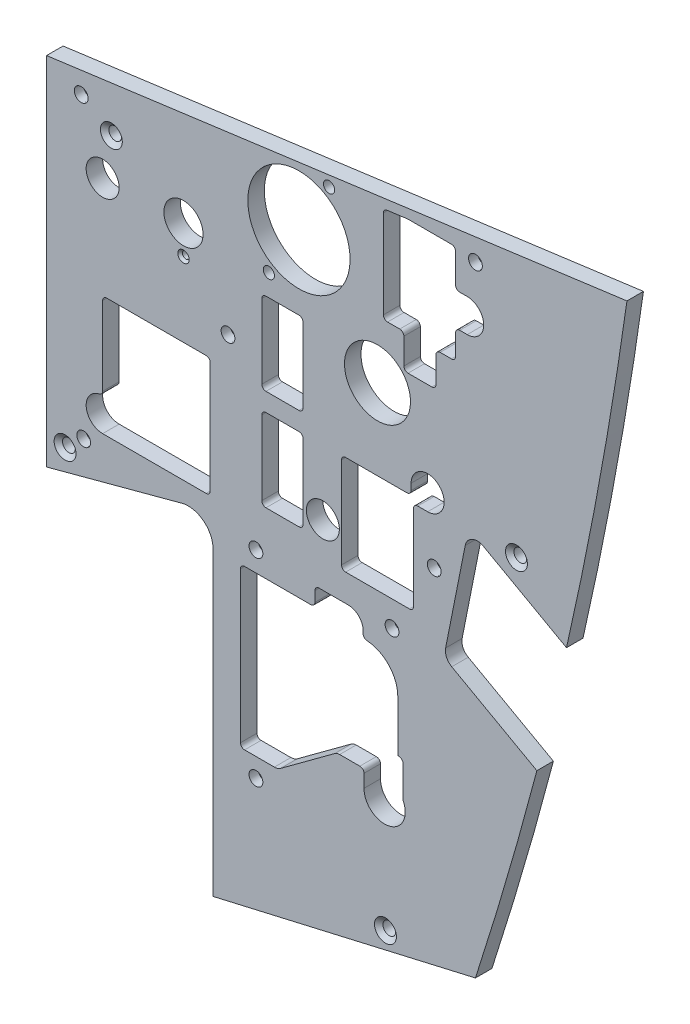
from build123d import *

# Parameters (mm, degrees)
BOSS_EXTRUDE1_DEPTH                               = 6.35
CUT_EXTRUDE1_DEPTH                                = 3445.149264037
SKETCH16_R                                        = 19.685
CUT_EXTRUDE2_DEPTH                                = 3441.935692786
HOLE1_AT_2_COUNT                                  = 2
HOLE1_AT_2_PITCH                                  = 119.24757236
HOLE1_AT_3_COUNT                                  = 2
HOLE1_AT_3_PITCH                                  = 110.986721534
HOLE1_AT_4_COUNT                                  = 2
HOLE1_AT_4_PITCH                                  = 153.074558064
HOLE1_AT_5_COUNT                                  = 2
HOLE1_AT_5_PITCH                                  = 201.938172537
HOLE1_AT_6_COUNT                                  = 2
HOLE1_AT_6_PITCH                                  = 141.789371247
HOLE1_AT_7_COUNT                                  = 2
HOLE1_AT_7_PITCH                                  = 161.907950567
HOLE1_AT_8_COUNT                                  = 2
HOLE1_AT_8_PITCH                                  = 230.363901281
F_6_CLEARANCE_HOLE1_D                             = 4.3053
SKETCH8_R                                         = 6.35
SKETCH8_W                                         = 15.875
SKETCH8_H                                         = 31.75
SKETCH8_R_2                                       = 12.7
BOSS_EXTRUDE4_DEPTH                               = 6.35
BOSS_EXTRUDE5_DEPTH                               = 6.35
FILLET1_R                                         = 1.5875
FILLET2_R                                         = 4.7625
CSK_FOR_8_FLAT_HEAD_MACHINE_SCREW_100_D           = 4.9149
CSK_FOR_8_FLAT_HEAD_MACHINE_SCREW_100_CSINK_D     = 8.4328
CSK_FOR_8_FLAT_HEAD_MACHINE_SCREW_100_CSINK_ANGLE = 100
F_9_16_CLEARANCE_HOLE1_D                          = 15.07998
CSK_FOR_2_FLAT_HEAD_MACHINE_SCREW1_D              = 2.7051
CSK_FOR_2_FLAT_HEAD_MACHINE_SCREW1_CSINK_D        = 4.3688
CSK_FOR_2_FLAT_HEAD_MACHINE_SCREW1_CSINK_ANGLE    = 82


with BuildPart() as part:
    # Sketch1 → Boss-Extrude1 (new body)
    with BuildSketch(Plane.XY):
        with BuildLine():
            Line((3063.004951447, 1044.559583645), (3063.004951447, 919.161653822))
            Line((3063.004951447, 919.161653822), (3164.268460554, 942.531700046))
            add(Edge.make_bspline(
                [(3164.268460554, 942.531700046), (3174.555103952, 973.758107079), (3183.862113846, 1005.38420927), (3192.178905159, 1037.697183634)],
                knots=[0.073605522, 0.073605522, 0.073605522, 0.073605522, 0.193443505, 0.193443505, 0.193443505, 0.193443505], degree=3))
            Line((3192.178905159, 1037.697183634), (3156.077631001, 1057.801137621))
            Line((3156.077631001, 1057.801137621), (3161.742294802, 1086.300863717))
            Line((3161.742294802, 1086.300863717), (3199.053930523, 1065.522887729))
            add(Edge.make_bspline(
                [(3199.053930523, 1065.522887729), (3209.83433854, 1111.042485424), (3218.693398597, 1158.04924886), (3225.6026318, 1207.31582086)],
                knots=[0.227626733, 0.227626733, 0.227626733, 0.227626733, 0.394301885, 0.394301885, 0.394301885, 0.394301885], degree=3))
            Line((3225.6026318, 1207.31582086), (2998.923757164, 1176.970694712))
            Line((2998.923757164, 1176.970694712), (2998.923757164, 1039.802301063))
            Line((2998.923757164, 1039.802301063), (3051.014700043, 1053.76002714))
            ThreePointArc((3051.014700043, 1053.76002714), (3059.278404059, 1052.116274211), (3063.004951447, 1044.559583645))
        make_face()
        with BuildLine():
            Line((3141.798754232, 1080.76821546), (3141.798754232, 1063.318414331))
            ThreePointArc((3141.798754232, 1063.318414331), (3141.330066584, 1062.18690214), (3140.19855446, 1061.718214331))
            Line((3140.19855446, 1061.718214331), (3005.273757092, 1061.718195164))
            ThreePointArc((3005.273757092, 1061.718195164), (3004.151224971, 1062.183163029), (3003.686256866, 1063.305695051))
            Line((3003.686256866, 1063.305695051), (3003.686245144, 1145.665194938))
            ThreePointArc((3003.686245144, 1145.665194938), (3004.151213016, 1146.787727075), (3005.273745054, 1147.252695186))
            Line((3005.273745054, 1147.252695186), (3005.908744671, 1147.252695254))
            ThreePointArc((3005.908744671, 1147.252695254), (3007.031276693, 1147.717663359), (3007.496244558, 1148.84019548))
            Line((3007.496244558, 1148.84019548), (3007.496242589, 1162.696016971))
            ThreePointArc((3007.496242589, 1162.696016971), (3007.961210415, 1163.818549052), (3009.083742364, 1164.283517197))
            Line((3009.083742364, 1164.283517197), (3012.258758066, 1164.283517648))
            ThreePointArc((3012.258758066, 1164.283517648), (3016.753873448, 1166.148383358), (3018.608741475, 1170.647633408))
            Line((3018.608741475, 1170.647633408), (3018.608740873, 1174.88088596))
            ThreePointArc((3018.608740873, 1174.88088596), (3019.002695145, 1175.927597629), (3019.989030664, 1176.454804919))
            Line((3019.989030664, 1176.454804919), (3036.868275535, 1178.676998342))
            ThreePointArc((3036.868275535, 1178.676998342), (3038.252348893, 1178.168513501), (3038.621106409, 1176.740846246))
            Line((3038.621106409, 1176.740846246), (3031.88970174, 1148.018483172))
            ThreePointArc((3031.88970174, 1148.018483172), (3031.806950167, 1147.214053621), (3031.930103254, 1146.414811455))
            Line((3031.930103254, 1146.414811455), (3037.83452165, 1125.926489722))
            ThreePointArc((3037.83452165, 1125.926489722), (3038.976284575, 1124.2687575), (3040.885361466, 1123.630694713))
            Line((3040.885361466, 1123.630694713), (3060.836248915, 1123.630694713))
            ThreePointArc((3060.836248915, 1123.630694713), (3061.95878093, 1123.165726728), (3062.423748915, 1122.043194713))
            Line((3062.423748915, 1122.043194713), (3062.423748915, 1118.868194713))
            ThreePointArc((3062.423748915, 1118.868194713), (3068.773748915, 1112.518194713), (3075.123748915, 1118.868194713))
            Line((3075.123748915, 1118.868194713), (3075.123748915, 1138.235694713))
            ThreePointArc((3075.123748915, 1138.235694713), (3075.5887169, 1139.358226728), (3076.711248915, 1139.823194713))
            Line((3076.711248915, 1139.823194713), (3108.256643371, 1139.823194713))
            ThreePointArc((3108.256643371, 1139.823194713), (3110.126802458, 1140.432433619), (3111.279245843, 1142.026341177))
            Line((3111.279245843, 1142.026341177), (3126.56576419, 1189.569583471))
            ThreePointArc((3126.56576419, 1189.569583471), (3127.060083558, 1190.302633376), (3127.869855096, 1190.657575421))
            Line((3127.869855096, 1190.657575421), (3155.879034385, 1194.345053829))
            ThreePointArc((3155.879034385, 1194.345053829), (3157.132956197, 1193.964680806), (3157.673744716, 1192.771135112))
            Line((3157.673744716, 1192.771135112), (3157.673744716, 1190.613729862))
            ThreePointArc((3157.673744716, 1190.613729862), (3159.533616655, 1186.123601801), (3164.023744716, 1184.263729862))
            Line((3164.023744716, 1184.263729862), (3167.198744716, 1184.263729862))
            ThreePointArc((3167.198744716, 1184.263729862), (3168.321276731, 1183.798761877), (3168.786244716, 1182.676229862))
            Line((3168.786244716, 1182.676229862), (3168.786244716, 1148.078239816))
            ThreePointArc((3168.786244716, 1148.078239816), (3168.321276811, 1146.955707881), (3167.198744941, 1146.490739816))
            Line((3167.198744941, 1146.490739816), (3162.436243814, 1146.490739139))
            ThreePointArc((3162.436243814, 1146.490739139), (3158.376709192, 1145.023641776), (3156.192988793, 1141.300261425))
            Line((3156.192988793, 1141.300261425), (3152.937962341, 1123.774429951))
            ThreePointArc((3152.937962341, 1123.774429951), (3152.917957765, 1123.63010065), (3152.911270795, 1123.484545113))
            Line((3152.911270795, 1123.484545113), (3152.911270795, 1088.70571546))
            ThreePointArc((3152.911270795, 1088.70571546), (3152.44630281, 1087.583183445), (3151.323770795, 1087.11821546))
            Line((3151.323770795, 1087.11821546), (3148.148754232, 1087.11821546))
            ThreePointArc((3148.148754232, 1087.11821546), (3143.658626172, 1085.258343521), (3141.798754232, 1080.76821546))
        make_face(mode=Mode.SUBTRACT)
        with BuildLine():
            Line((3086.087201447, 970.357569713), (3119.749985468, 970.357569713))
            ThreePointArc((3119.749985468, 970.357569713), (3120.138791835, 970.434908108), (3120.468405958, 970.655149223))
            Line((3120.468405958, 970.655149223), (3137.557996937, 987.744740203))
            ThreePointArc((3137.557996937, 987.744740203), (3137.778238052, 988.074354325), (3137.855576447, 988.463160692))
            Line((3137.855576447, 988.463160692), (3137.855576447, 1045.938444713))
            ThreePointArc((3137.855576447, 1045.938444713), (3137.557996937, 1046.656865203), (3136.839576447, 1046.954444713))
            Line((3136.839576447, 1046.954444713), (3131.108701447, 1046.954444713))
            ThreePointArc((3131.108701447, 1046.954444713), (3127.741105402, 1048.349348668), (3126.346201447, 1051.716944713))
            Line((3126.346201447, 1051.716944713), (3126.346201447, 1057.447819713))
            ThreePointArc((3126.346201447, 1057.447819713), (3126.048621937, 1058.166240203), (3125.330201447, 1058.463819713))
            Line((3125.330201447, 1058.463819713), (3085.293451447, 1058.463819713))
            ThreePointArc((3085.293451447, 1058.463819713), (3084.575030958, 1058.166240203), (3084.277451447, 1057.447819713))
            Line((3084.277451447, 1057.447819713), (3084.277451447, 1052.510694713))
            ThreePointArc((3084.277451447, 1052.510694713), (3082.882547493, 1049.143098667), (3079.514951447, 1047.748194713))
            Line((3079.514951447, 1047.748194713), (3074.577826447, 1047.748194713))
            ThreePointArc((3074.577826447, 1047.748194713), (3073.859405958, 1047.450615203), (3073.561826447, 1046.732194713))
            Line((3073.561826447, 1046.732194713), (3073.561826447, 982.882944713))
            ThreePointArc((3073.561826447, 982.882944713), (3073.859405958, 982.164524223), (3074.577826447, 981.866944713))
            Line((3074.577826447, 981.866944713), (3080.308701447, 981.866944713))
            ThreePointArc((3080.308701447, 981.866944713), (3083.676297493, 980.472040758), (3085.071201447, 977.104444713))
            Line((3085.071201447, 977.104444713), (3085.071201447, 971.373569713))
            ThreePointArc((3085.071201447, 971.373569713), (3085.368780958, 970.655149223), (3086.087201447, 970.357569713))
        make_face(mode=Mode.SUBTRACT)
    extrude(amount=-BOSS_EXTRUDE1_DEPTH)

    # Sketch2 → Cut-Extrude1 (cut, through all)
    with BuildSketch(Plane.XY):
        with BuildLine():
            Line((3192.178905159, 1037.697183634), (3156.077631001, 1057.801137621))
            Line((3156.077631001, 1057.801137621), (3161.742294802, 1086.300863717))
            Line((3161.742294802, 1086.300863717), (3199.053930523, 1065.522887729))
            add(Edge.make_bspline(
                [(3199.053930523, 1065.522887729), (3209.83433854, 1111.042485424), (3218.693398597, 1158.04924886), (3225.602631801, 1207.31582086)],
                knots=[0.227626733, 0.227626733, 0.227626733, 0.227626733, 0.394301885, 0.394301885, 0.394301885, 0.394301885], degree=3))
            Line((3225.602631801, 1207.31582086), (3222.334973685, 1206.878384871))
            add(Edge.make_bspline(
                [(3199.066872029, 1079.630557452), (3199.348827276, 1080.872127049), (3200.919170922, 1087.829294258), (3204.958331198, 1106.340377978), (3209.61532338, 1129.652293978), (3213.911729082, 1153.321830635), (3216.952381515, 1171.25706578), (3219.335387039, 1186.36829019), (3221.106417414, 1198.260437059), (3221.944482294, 1204.104861355), (3222.334973685, 1206.878384871)],
                knots=[0.243930295, 0.243930295, 0.243930295, 0.243930295, 0.248461127, 0.269295521, 0.310964309, 0.331798703, 0.352633097, 0.373467491, 0.383884688, 0.393307081, 0.393307081, 0.393307081, 0.393307081], degree=3))
            Line((3199.066872029, 1079.630557452), (3161.353699672, 1100.632139788))
            Line((3161.353699672, 1100.632139788), (3151.862439008, 1052.880262758))
            Line((3151.862439008, 1052.880262758), (3187.665173517, 1032.942558509))
            add(Edge.make_bspline(
                [(3164.016888783, 951.998641164), (3165.625997339, 956.980849059), (3169.69138435, 969.794206523), (3175.977462125, 990.567604952), (3181.626956674, 1010.422414131), (3185.462648104, 1024.578734882), (3187.09667721, 1030.768886559), (3187.665173517, 1032.942558509)],
                knots=[0.084451096, 0.084451096, 0.084451096, 0.084451096, 0.103565018, 0.133524514, 0.163484009, 0.178463757, 0.186560537, 0.186560537, 0.186560537, 0.186560537], degree=3))
            Line((3164.016888783, 951.998641164), (3063.004951447, 928.686653822))
            Line((3063.004951447, 928.686653822), (3063.004951447, 919.161653822))
            Line((3063.004951447, 919.161653822), (3164.268460554, 942.531700046))
            add(Edge.make_bspline(
                [(3164.268460554, 942.531700046), (3174.555103952, 973.758107079), (3183.862113846, 1005.38420927), (3192.178905159, 1037.697183634)],
                knots=[0.073605522, 0.073605522, 0.073605522, 0.073605522, 0.193443505, 0.193443505, 0.193443505, 0.193443505], degree=3))
        make_face()
    extrude(amount=-CUT_EXTRUDE1_DEPTH, mode=Mode.SUBTRACT)

    # Sketch16 → Cut-Extrude2 (cut, through all)
    with BuildSketch(Plane(origin=(0, 0, -6.35), x_dir=(-1, 0, 0), z_dir=(0, 0, -1))):
        with Locations(Location((-3096.078757164, 1167.445694712, 0), (0, 0, 90))):
            Circle(SKETCH16_R)
    extrude(amount=-CUT_EXTRUDE2_DEPTH, mode=Mode.SUBTRACT)

    # Sketch5 → Hole1 (revolve, cut)
    with BuildSketch(Plane(origin=(3164.023744716, 1190.613729862, 0), x_dir=(0, -1, 0), z_dir=(1, 0, 0))):
        Polygon((0, 0), (0, 3.429), (2.5273, 3.429), (2.6543, 0), align=None)
    hole1 = revolve(axis=Axis((3164.023744716, 1190.613729862, -110), (0, 0, 1)), mode=Mode.SUBTRACT)

    # Hole1 at 2: Hole1 ×2
    with Locations(*[Vector(-0.7987583639260228, -0.601651955916561, 0) * (i * HOLE1_AT_2_PITCH) for i in range(1, HOLE1_AT_2_COUNT)]):
        add(hole1, mode=Mode.SUBTRACT)

    # Hole1 at 3: Hole1 ×2
    with Locations(*[Vector(-0.14303504296543185, -0.9897176246202132, 0) * (i * HOLE1_AT_3_PITCH) for i in range(1, HOLE1_AT_3_COUNT)]):
        add(hole1, mode=Mode.SUBTRACT)

    # Hole1 at 4: Hole1 ×2
    with Locations(*[Vector(-0.9914448845748092, -0.13052601599084906, 0) * (i * HOLE1_AT_4_PITCH) for i in range(1, HOLE1_AT_4_COUNT)]):
        add(hole1, mode=Mode.SUBTRACT)

    # Hole1 at 5: Hole1 ×2
    with Locations(*[Vector(-0.7468250559832259, -0.6650205528821282, 0) * (i * HOLE1_AT_5_PITCH) for i in range(1, HOLE1_AT_5_COUNT)]):
        add(hole1, mode=Mode.SUBTRACT)

    # Hole1 at 6: Hole1 ×2
    with Locations(*[Vector(-0.2265423210908874, -0.9740013227684824, 0) * (i * HOLE1_AT_6_PITCH) for i in range(1, HOLE1_AT_6_COUNT)]):
        add(hole1, mode=Mode.SUBTRACT)

    # Hole1 at 7: Hole1 ×2
    with Locations(*[Vector(-0.52195579631539, -0.852972535720094, 0) * (i * HOLE1_AT_7_PITCH) for i in range(1, HOLE1_AT_7_COUNT)]):
        add(hole1, mode=Mode.SUBTRACT)

    # Hole1 at 8: Hole1 ×2
    with Locations(*[Vector(-0.36684911480554966, -0.9302804560810599, 0) * (i * HOLE1_AT_8_PITCH) for i in range(1, HOLE1_AT_8_COUNT)]):
        add(hole1, mode=Mode.SUBTRACT)

    # #6 Clearance Hole1 (through all)
    with Locations(Plane.XY):
        with Locations((3079.514951447, 976.310694713), (3079.514951447, 1052.510694713), (3131.902451447, 1052.510694713), (3013.211257705, 1056.320694713), (3012.258757164, 1170.633517648), (3068.773748915, 1118.868194713), (3148.148754232, 1080.76821546), (3164.023744716, 1190.613729862), (3107.667507164, 1187.517998508), (3084.490007164, 1147.373390916)):
            Hole(F_6_CLEARANCE_HOLE1_D / 2)

    # Sketch8 → Boss-Extrude4 (add)
    with BuildSketch(Plane(origin=(0, 0, -6.35), x_dir=(-1, 0, 0), z_dir=(0, 0, -1))):
        with BuildLine():
            Line((-3020.513756037, 1107.681631415), (-3020.513756037, 1074.418198411))
            ThreePointArc((-3020.513756037, 1074.418198411), (-3014.163755495, 1068.068197829), (-3020.51375612, 1061.718197329))
            Line((-3020.51375612, 1061.718197329), (-3005.273757092, 1061.718195164))
            ThreePointArc((-3005.273757092, 1061.718195164), (-3004.151224971, 1062.183163029), (-3003.686256866, 1063.305695051))
            Line((-3003.686256866, 1063.305695051), (-3003.686245144, 1145.665194938))
            ThreePointArc((-3003.686245144, 1145.665194938), (-3004.151213016, 1146.787727075), (-3005.273745054, 1147.252695186))
            Line((-3005.273745054, 1147.252695186), (-3005.908744671, 1147.252695254))
            ThreePointArc((-3005.908744671, 1147.252695254), (-3007.031276693, 1147.717663359), (-3007.496244558, 1148.84019548))
            Line((-3007.496244558, 1148.84019548), (-3007.496242589, 1162.696016971))
            ThreePointArc((-3007.496242589, 1162.696016971), (-3007.961210415, 1163.818549052), (-3009.083742364, 1164.283517197))
            Line((-3009.083742364, 1164.283517197), (-3012.258758066, 1164.283517648))
            ThreePointArc((-3012.258758066, 1164.283517648), (-3016.753873448, 1166.148383358), (-3018.608741475, 1170.647633408))
            Line((-3018.608741475, 1170.647633408), (-3018.608740873, 1174.88088596))
            ThreePointArc((-3018.608740873, 1174.88088596), (-3019.002695145, 1175.927597629), (-3019.989030664, 1176.454804919))
            Line((-3019.989030664, 1176.454804919), (-3036.868275535, 1178.676998342))
            ThreePointArc((-3036.868275535, 1178.676998342), (-3038.252348893, 1178.168513501), (-3038.621106409, 1176.740846246))
            Line((-3038.621106409, 1176.740846246), (-3031.88970174, 1148.018483172))
            ThreePointArc((-3031.88970174, 1148.018483172), (-3031.806950167, 1147.214053621), (-3031.930103254, 1146.414811455))
            Line((-3031.930103254, 1146.414811455), (-3037.83452165, 1125.926489722))
            ThreePointArc((-3037.83452165, 1125.926489722), (-3038.976284575, 1124.2687575), (-3040.885361466, 1123.630694713))
            Line((-3040.885361466, 1123.630694713), (-3060.836248915, 1123.630694713))
            ThreePointArc((-3060.836248915, 1123.630694713), (-3061.95878093, 1123.165726728), (-3062.423748915, 1122.043194713))
            Line((-3062.423748915, 1122.043194713), (-3062.423748915, 1118.868194713))
            ThreePointArc((-3062.423748915, 1118.868194713), (-3068.773748915, 1112.518194713), (-3075.123748915, 1118.868194713))
            Line((-3075.123748915, 1118.868194713), (-3075.123748915, 1138.235694713))
            ThreePointArc((-3075.123748915, 1138.235694713), (-3075.5887169, 1139.358226728), (-3076.711248915, 1139.823194713))
            Line((-3076.711248915, 1139.823194713), (-3108.256643371, 1139.823194713))
            ThreePointArc((-3108.256643371, 1139.823194713), (-3110.126802458, 1140.432433619), (-3111.279245843, 1142.026341177))
            Line((-3111.279245843, 1142.026341177), (-3126.56576419, 1189.569583471))
            ThreePointArc((-3126.56576419, 1189.569583471), (-3127.060083558, 1190.302633376), (-3127.869855096, 1190.657575421))
            Line((-3127.869855096, 1190.657575421), (-3128.588447605, 1190.752179919))
            Line((-3128.588447605, 1190.752179919), (-3128.588447605, 1153.771047149))
            Line((-3128.588447605, 1153.771047149), (-3136.469706644, 1153.771047149))
            Line((-3136.469706644, 1153.771047149), (-3136.469706644, 1140.63864551))
            Line((-3136.469706644, 1140.63864551), (-3148.824486801, 1140.63864551))
            Line((-3148.824486801, 1140.63864551), (-3148.824486801, 1153.771047149))
            Line((-3148.824486801, 1153.771047149), (-3156.379047605, 1153.771047149))
            Line((-3156.379047605, 1153.771047149), (-3156.379047605, 1164.905716362))
            Line((-3156.379047605, 1164.905716362), (-3160.848758292, 1164.905716362))
            ThreePointArc((-3160.848758292, 1164.905716362), (-3167.198758292, 1171.255716362), (-3160.848758292, 1177.605716362))
            Line((-3160.848758292, 1177.605716362), (-3156.379047605, 1177.605716362))
            Line((-3156.379047605, 1177.605716362), (-3156.379047605, 1191.988194556))
            Line((-3156.379047605, 1191.988194556), (-3137.976910864, 1191.988194556))
            Line((-3137.976910864, 1191.988194556), (-3155.879034385, 1194.345053829))
            ThreePointArc((-3155.879034385, 1194.345053829), (-3157.132956197, 1193.964680806), (-3157.673744716, 1192.771135112))
            Line((-3157.673744716, 1192.771135112), (-3157.673744716, 1190.613729862))
            ThreePointArc((-3157.673744716, 1190.613729862), (-3159.533616655, 1186.123601801), (-3164.023744716, 1184.263729862))
            Line((-3164.023744716, 1184.263729862), (-3167.198744716, 1184.263729862))
            ThreePointArc((-3167.198744716, 1184.263729862), (-3168.321276731, 1183.798761877), (-3168.786244716, 1182.676229862))
            Line((-3168.786244716, 1182.676229862), (-3168.786244716, 1148.078239816))
            ThreePointArc((-3168.786244716, 1148.078239816), (-3168.321276811, 1146.955707881), (-3167.198744941, 1146.490739816))
            Line((-3167.198744941, 1146.490739816), (-3162.436243814, 1146.490739139))
            ThreePointArc((-3162.436243814, 1146.490739139), (-3158.376709192, 1145.023641776), (-3156.192988793, 1141.300261425))
            Line((-3156.192988793, 1141.300261425), (-3152.937962341, 1123.774429951))
            ThreePointArc((-3152.937962341, 1123.774429951), (-3152.917957765, 1123.63010065), (-3152.911270795, 1123.484545113))
            Line((-3152.911270795, 1123.484545113), (-3152.911270795, 1088.70571546))
            ThreePointArc((-3152.911270795, 1088.70571546), (-3152.44630281, 1087.583183445), (-3151.323770795, 1087.11821546))
            Line((-3151.323770795, 1087.11821546), (-3148.148754232, 1087.11821546))
            ThreePointArc((-3148.148754232, 1087.11821546), (-3143.658626172, 1085.258343521), (-3141.798754232, 1080.76821546))
            Line((-3141.798754232, 1080.76821546), (-3141.798754232, 1063.318414331))
            ThreePointArc((-3141.798754232, 1063.318414331), (-3141.330066584, 1062.18690214), (-3140.19855446, 1061.718214331))
            Line((-3140.19855446, 1061.718214331), (-3061.926971874, 1061.71819787))
            Line((-3061.926971874, 1061.71819787), (-3061.926971874, 1107.681631415))
            Line((-3061.926971874, 1107.681631415), (-3020.513756037, 1107.681631415))
        make_face()
        with BuildLine():
            Line((-3112.459456626, 1062.331068799), (-3140.200056626, 1062.331068799))
            Line((-3140.200056626, 1062.331068799), (-3140.200056626, 1098.230715099))
            Line((-3140.200056626, 1098.230715099), (-3145.608758292, 1098.230715099))
            ThreePointArc((-3145.608758292, 1098.230715099), (-3150.098886352, 1109.07084316), (-3139.258758292, 1104.580715099))
            Line((-3139.258758292, 1104.580715099), (-3139.258758292, 1100.548216205))
            Line((-3139.258758292, 1100.548216205), (-3112.459456626, 1100.548216205))
            Line((-3112.459456626, 1100.548216205), (-3112.459456626, 1062.331068799))
        make_face(mode=Mode.SUBTRACT)
        with Locations(Location((-3105.286254999, 1075.370709371, 0), (0, 0, 90))):
            Circle(SKETCH8_R, mode=Mode.SUBTRACT)
        with Locations((-3089.728757164, 1084.310716418)):
            Rectangle(SKETCH8_W, SKETCH8_H, mode=Mode.SUBTRACT)
        with Locations((-3089.728757221, 1123.122716078)):
            Rectangle(SKETCH8_W, SKETCH8_H, mode=Mode.SUBTRACT)
        with Locations(Location((-3126.304753736, 1131.568216137, 0), (0, 0, 90))):
            Circle(SKETCH8_R_2, mode=Mode.SUBTRACT)
        with Locations(Location((-3020.513744842, 1146.87169787, 0), (0, 0, 90))):
            Circle(SKETCH8_R, mode=Mode.SUBTRACT)
        Polygon((-3128.588447605, 1191.988194556), (-3137.976910864, 1191.988194556), (-3128.588447605, 1190.752179919), align=None)
    extrude(amount=-BOSS_EXTRUDE4_DEPTH)

    # Sketch9 → Boss-Extrude5 (add)
    with BuildSketch(Plane(origin=(0, 0, -6.35), x_dir=(-1, 0, 0), z_dir=(0, 0, -1))):
        with BuildLine():
            Line((-3111.751124589, 1000.371317539), (-3121.107451447, 1000.371317539))
            Line((-3121.107451447, 1000.371317539), (-3121.107451447, 993.773194713))
            ThreePointArc((-3121.107451447, 993.773194713), (-3130.882615556, 986.051349281), (-3136.131551447, 997.348667645))
            Line((-3136.131551447, 997.348667645), (-3136.131551447, 1011.166317539))
            Line((-3136.131551447, 1011.166317539), (-3134.124951447, 1011.166317539))
            Line((-3134.124951447, 1011.166317539), (-3134.124951447, 1030.920694713))
            ThreePointArc((-3134.124951447, 1030.920694713), (-3130.177822405, 1040.122718947), (-3120.789951447, 1043.604809779))
            Line((-3120.789951447, 1043.604809779), (-3120.789951447, 1046.160694713))
            ThreePointArc((-3120.789951447, 1046.160694713), (-3119.116066702, 1050.201809967), (-3115.074951447, 1051.875694713))
            Line((-3115.074951447, 1051.875694713), (-3102.247951447, 1051.875694713))
            Line((-3102.247951447, 1051.875694713), (-3102.247951447, 1044.771182058))
            Line((-3102.247951447, 1044.771182058), (-3082.181951447, 1044.771182058))
            Line((-3082.181951447, 1044.771182058), (-3073.561826447, 1044.771182058))
            Line((-3073.561826447, 1044.771182058), (-3073.561826447, 1046.732194713))
            ThreePointArc((-3073.561826447, 1046.732194713), (-3073.859405958, 1047.450615203), (-3074.577826447, 1047.748194713))
            Line((-3074.577826447, 1047.748194713), (-3079.514951447, 1047.748194713))
            ThreePointArc((-3079.514951447, 1047.748194713), (-3082.882547493, 1049.143098667), (-3084.277451447, 1052.510694713))
            Line((-3084.277451447, 1052.510694713), (-3084.277451447, 1057.447819713))
            ThreePointArc((-3084.277451447, 1057.447819713), (-3084.575030958, 1058.166240203), (-3085.293451447, 1058.463819713))
            Line((-3085.293451447, 1058.463819713), (-3125.330201447, 1058.463819713))
            ThreePointArc((-3125.330201447, 1058.463819713), (-3126.048621937, 1058.166240203), (-3126.346201447, 1057.447819713))
            Line((-3126.346201447, 1057.447819713), (-3126.346201447, 1051.716944713))
            ThreePointArc((-3126.346201447, 1051.716944713), (-3127.741105402, 1048.349348668), (-3131.108701447, 1046.954444713))
            Line((-3131.108701447, 1046.954444713), (-3136.839576447, 1046.954444713))
            ThreePointArc((-3136.839576447, 1046.954444713), (-3137.557996937, 1046.656865203), (-3137.855576447, 1045.938444713))
            Line((-3137.855576447, 1045.938444713), (-3137.855576447, 988.463160692))
            ThreePointArc((-3137.855576447, 988.463160692), (-3137.778238052, 988.074354325), (-3137.557996937, 987.744740203))
            Line((-3137.557996937, 987.744740203), (-3120.468405958, 970.655149223))
            ThreePointArc((-3120.468405958, 970.655149223), (-3120.138791835, 970.434908108), (-3119.749985468, 970.357569713))
            Line((-3119.749985468, 970.357569713), (-3086.087201447, 970.357569713))
            ThreePointArc((-3086.087201447, 970.357569713), (-3085.368780958, 970.655149223), (-3085.071201447, 971.373569713))
            Line((-3085.071201447, 971.373569713), (-3085.071201447, 977.104444713))
            ThreePointArc((-3085.071201447, 977.104444713), (-3083.676297493, 980.472040758), (-3080.308701447, 981.866944713))
            Line((-3080.308701447, 981.866944713), (-3074.577826447, 981.866944713))
            ThreePointArc((-3074.577826447, 981.866944713), (-3073.859405958, 982.164524223), (-3073.561826447, 982.882944713))
            Line((-3073.561826447, 982.882944713), (-3073.561826447, 983.613194713))
            Line((-3073.561826447, 983.613194713), (-3086.617425772, 983.613194713))
            ThreePointArc((-3086.617425772, 983.613194713), (-3087.906471358, 983.819646673), (-3089.066564314, 984.41834966))
            Line((-3089.066564314, 984.41834966), (-3109.867171864, 999.75196758))
            ThreePointArc((-3109.867171864, 999.75196758), (-3110.759551061, 1000.212508339), (-3111.751124589, 1000.371317539))
        make_face()
    extrude(amount=-BOSS_EXTRUDE5_DEPTH)

    # Fillet1
    fillet1_edges = [part.edges().sort_by_distance(p)[0] for p in [
        (3139.258758292, 1100.548216205, -3.175),
        (3112.459456626, 1100.548216205, -3.175),
        (3112.459456626, 1062.331068799, -3.175),
        (3140.200056626, 1062.331068799, -3.175),
        (3140.200056626, 1098.230715099, -3.175),
        (3081.791257221, 1107.247716078, -3.175),
        (3097.666257221, 1107.247716078, -3.175),
        (3097.666257221, 1138.997716078, -3.175),
        (3081.791257221, 1138.997716078, -3.175),
        (3081.791257164, 1068.435716418, -3.175),
        (3097.666257164, 1068.435716418, -3.175),
        (3097.666257164, 1100.185716418, -3.175),
        (3081.791257164, 1100.185716418, -3.175),
        (3061.926971874, 1061.718203212, -3.175),
        (3061.926971874, 1107.681631415, -3.175),
        (3020.513756037, 1107.681631415, -3.175),
        (3020.513756037, 1074.418198411, -3.175),
        (3128.588447605, 1190.752179919, -3.175),
        (3128.588447605, 1153.771047149, -3.175),
        (3136.469706644, 1153.771047149, -3.175),
        (3136.469706644, 1140.63864551, -3.175),
        (3148.824486801, 1140.63864551, -3.175),
        (3148.824486801, 1153.771047149, -3.175),
        (3156.379047605, 1153.771047149, -3.175),
        (3156.379047605, 1164.905716362, -3.175),
        (3156.379047605, 1177.605716362, -3.175),
        (3156.379047605, 1191.988194556, -3.175),
        (3137.976910864, 1191.988194556, -3.175),
        (3120.789951447, 1043.604809779, -3.175),
        (3136.131551447, 1011.166317539, -3.175),
        (3136.131551447, 997.348667645, -3.175),
        (3121.107451447, 1000.371317539, -3.175),
        (3073.561826447, 983.613194713, -3.175),
        (3073.561826447, 1044.771182058, -3.175),
        (3102.247951447, 1044.771182058, -3.175),
        (3102.247951447, 1051.875694713, -3.175),
    ]]
    fillet(fillet1_edges, radius=FILLET1_R)

    # Fillet2
    fillet2_edges = [part.edges().sort_by_distance(p)[0] for p in [
        (3151.862439008, 1052.880262758, -3.175),
        (3161.353699672, 1100.632139788, -3.175),
    ]]
    fillet(fillet2_edges, radius=FILLET2_R)

    # CSK for #8 Flat Head Machine Screw (100) (through all)
    with Locations(Plane.XY):
        with Locations((3129.381008851, 950.522129182), (3179.805127216, 1100.045474787), (3023.864360405, 1162.74669787), (3006.046436056, 1049.88821717)):
            CounterSinkHole(CSK_FOR_8_FLAT_HEAD_MACHINE_SCREW_100_D / 2, CSK_FOR_8_FLAT_HEAD_MACHINE_SCREW_100_CSINK_D / 2, counter_sink_angle=CSK_FOR_8_FLAT_HEAD_MACHINE_SCREW_100_CSINK_ANGLE)

    # 9/16 Clearance Hole1 (through all)
    with Locations(Plane.XY):
        with Locations((3051.628757164, 1147.443194712)):
            Hole(F_9_16_CLEARANCE_HOLE1_D / 2)

    # CSK for #2 Flat Head Machine Screw1 (through all)
    with Locations(Plane.XY):
        with Locations((3051.628758749, 1136.330694712)):
            CounterSinkHole(CSK_FOR_2_FLAT_HEAD_MACHINE_SCREW1_D / 2, CSK_FOR_2_FLAT_HEAD_MACHINE_SCREW1_CSINK_D / 2, counter_sink_angle=CSK_FOR_2_FLAT_HEAD_MACHINE_SCREW1_CSINK_ANGLE)


solid = part.part
